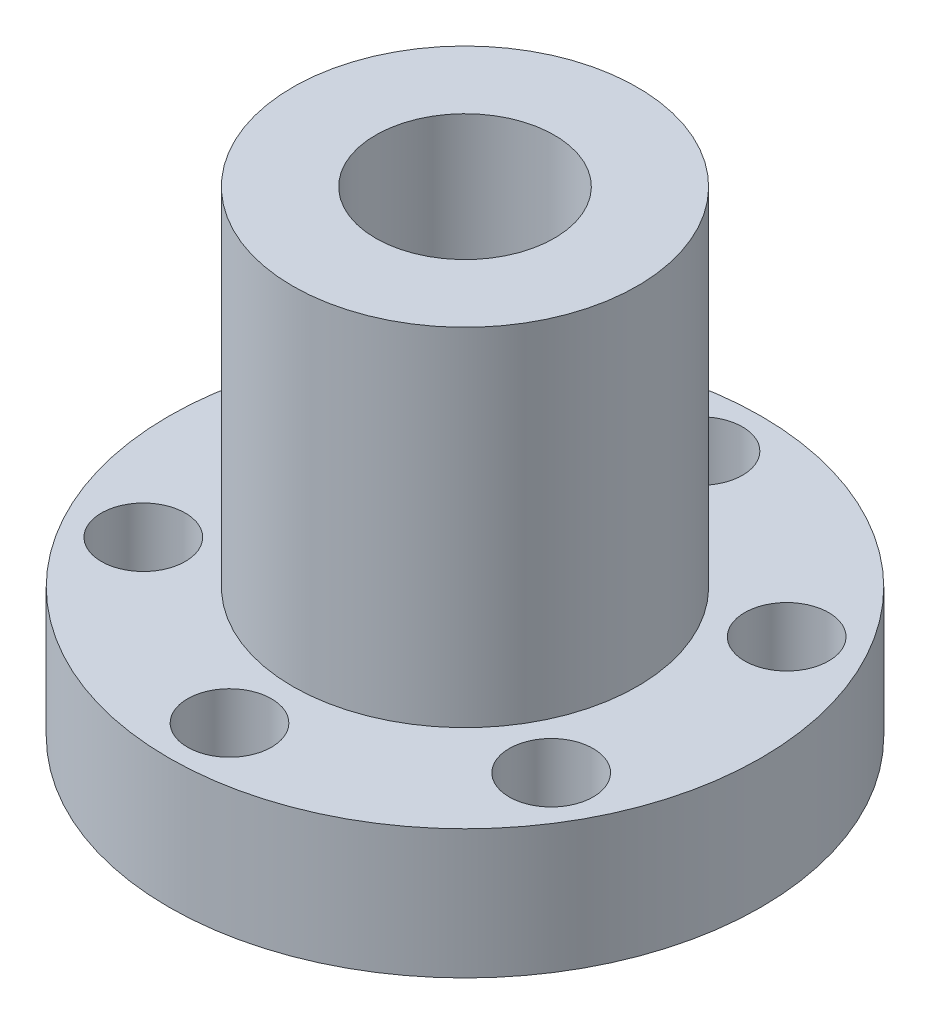
from build123d import *

# Parameters (mm, degrees)
SKETCH1_R           = 27.5
SKETCH1_R_2         = 16
BOSS_EXTRUDE1_DEPTH = 12
SKETCH1_2_R         = 16
BOSS_EXTRUDE2_DEPTH = 44.2
SKETCH3_R           = 8.3
SKETCH3_R_2         = 3.9
CUT_EXTRUDE1_DEPTH  = 59.873933111


with BuildPart() as part:
    # Sketch1 → Boss-Extrude1 (new body)
    with BuildSketch(Plane(origin=(0, 0, 0), x_dir=(1, 0, 0), z_dir=(0, 1, 0))):
        Circle(SKETCH1_R)
        Circle(SKETCH1_R_2, mode=Mode.SUBTRACT)
    extrude(amount=BOSS_EXTRUDE1_DEPTH)

    # Sketch1_2 → Boss-Extrude2 (add)
    with BuildSketch(Plane(origin=(0, 0, 0), x_dir=(1, 0, 0), z_dir=(0, 1, 0))):
        Circle(SKETCH1_2_R)
    extrude(amount=BOSS_EXTRUDE2_DEPTH)

    # Sketch3 → Cut-Extrude1 (cut, through all)
    with BuildSketch(Plane(origin=(0, 0, 0), x_dir=(1, 0, 0), z_dir=(0, 1, 0))):
        Circle(SKETCH3_R)
        with Locations((0, -21.869969165)):
            Circle(SKETCH3_R_2)
        with Locations((-18.939948877, -10.934984583)):
            Circle(SKETCH3_R_2)
        with Locations((-18.939948877, 10.934984583)):
            Circle(SKETCH3_R_2)
        with Locations((0, 21.869969165)):
            Circle(SKETCH3_R_2)
        with Locations((18.939948877, 10.934984583)):
            Circle(SKETCH3_R_2)
        with Locations((18.939948877, -10.934984583)):
            Circle(SKETCH3_R_2)
    extrude(amount=CUT_EXTRUDE1_DEPTH, mode=Mode.SUBTRACT)


solid = part.part
